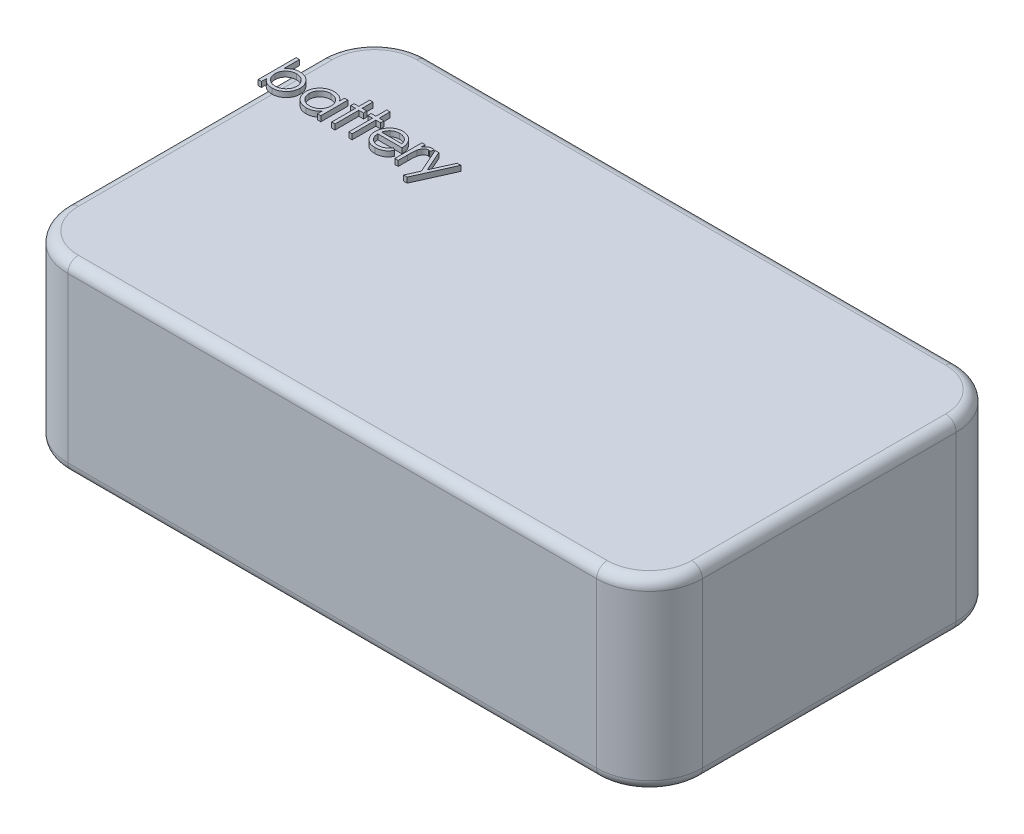
from build123d import *

# Parameters (mm, degrees)
SKETCH1_W           = 60
SKETCH1_H           = 34
BOSS_EXTRUDE1_DEPTH = 17.5
FILLET1_R           = 5
FILLET2_R           = 1
BOSS_EXTRUDE2_DEPTH = 0.5


with BuildPart() as part:
    # Sketch1 → Boss-Extrude1 (new body)
    with BuildSketch(Plane(origin=(0, 0, 0), x_dir=(1, 0, 0), z_dir=(0, 1, 0))):
        Rectangle(SKETCH1_W, SKETCH1_H)
    extrude(amount=BOSS_EXTRUDE1_DEPTH)

    # Fillet1
    fillet1_edges = [part.edges().sort_by_distance(p)[0] for p in [
        (30, 8.75, 17),
        (-30, 8.75, 17),
        (-30, 8.75, -17),
        (30, 8.75, -17),
    ]]
    fillet(fillet1_edges, radius=FILLET1_R)

    # Fillet2
    fillet2_edges = [part.edges().sort_by_distance(p)[0] for p in [
        (-30, 0, 0),
        (-30, 17.5, 0),
        (30, 0, 0),
        (0, 0, 17),
        (0, 0, -17),
        (-28.535533906, 0, 15.535533906),
        (28.535533906, 0, 15.535533906),
        (28.535533906, 0, -15.535533906),
        (-28.535533906, 0, -15.535533906),
        (0, 17.5, -17),
        (30, 17.5, 0),
        (0, 17.5, 17),
        (-28.535533906, 17.5, 15.535533906),
        (28.535533906, 17.5, 15.535533906),
        (28.535533906, 17.5, -15.535533906),
        (-28.535533906, 17.5, -15.535533906),
    ]]
    fillet(fillet2_edges, radius=FILLET2_R)

    # Sketch2 → Boss-Extrude2 (add)
    with BuildSketch(Plane(origin=(0, 17.5, 0), x_dir=(1, 0, 0), z_dir=(0, 1, 0))):
        with BuildLine():
            Line((-30.381480596, 6.382580887), (-30.381480596, 9.972324477))
            Line((-30.381480596, 9.972324477), (-30.067378032, 9.972324477))
            Line((-30.067378032, 9.972324477), (-30.067378032, 8.476130567))
            add(Edge.make_bspline(
                [(-30.067378032, 8.476130567), (-30.031984613, 8.516888499), (-29.962930593, 8.596408904), (-29.847154142, 8.700256554), (-29.725748572, 8.788309031), (-29.597790316, 8.86089515), (-29.463097383, 8.916168757), (-29.322365275, 8.956591147), (-29.175234234, 8.98097805), (-29.07491506, 8.983744123), (-29.024108801, 8.98514499)],
                knots=[0, 0, 0, 0, 0.000161815, 0.000315708, 0.000465351, 0.000611017, 0.000755934, 0.000901068, 0.001049529, 0.001201867, 0.001201867, 0.001201867, 0.001201867], degree=3))
            add(Edge.make_bspline(
                [(-29.024108801, 8.98514499), (-28.978942663, 8.983904762), (-28.889641511, 8.981452619), (-28.758359364, 8.962818124), (-28.632046089, 8.932600322), (-28.510770441, 8.890708143), (-28.395098308, 8.835125165), (-28.284039251, 8.768583858), (-28.178162267, 8.689345528), (-28.079107381, 8.598747218), (-27.987813495, 8.500390595), (-27.907900985, 8.39521028), (-27.840401289, 8.284735189), (-27.784569996, 8.169335127), (-27.741398943, 8.048538776), (-27.711656676, 7.922464577), (-27.692763212, 7.791236559), (-27.690382966, 7.701923755), (-27.689172903, 7.656519189)],
                knots=[0, 0, 0, 0, 0.000135464, 0.000267835, 0.000396906, 0.000524625, 0.000651952, 0.000781211, 0.000912462, 0.00104796, 0.001183414, 0.001314526, 0.001443549, 0.001571179, 0.00169847, 0.001827542, 0.001959218, 0.002095382, 0.002095382, 0.002095382, 0.002095382], degree=3))
            add(Edge.make_bspline(
                [(-27.689172903, 7.656519189), (-27.690409344, 7.611819171), (-27.69284741, 7.523677776), (-27.711468718, 7.393971219), (-27.742214983, 7.26913252), (-27.786176166, 7.149484263), (-27.841441105, 7.03446435), (-27.91055238, 6.925383946), (-27.99036338, 6.82034497), (-28.082694528, 6.722721338), (-28.182608081, 6.632487938), (-28.289522324, 6.554082073), (-28.400744246, 6.486364953), (-28.518007358, 6.432709506), (-28.639575399, 6.389308584), (-28.766750786, 6.359190893), (-28.898814014, 6.341617838), (-28.988532903, 6.339022271), (-29.033924506, 6.337709093)],
                knots=[0, 0, 0, 0, 0.000134063, 0.000264351, 0.000392226, 0.000519096, 0.000646094, 0.000774294, 0.000905831, 0.001041249, 0.001176798, 0.001309174, 0.001438434, 0.001566731, 0.001695345, 0.001825098, 0.001958069, 0.002094233, 0.002094233, 0.002094233, 0.002094233], degree=3))
            add(Edge.make_bspline(
                [(-29.033924506, 6.337709093), (-29.085889618, 6.339149701), (-29.187784143, 6.341974482), (-29.336836808, 6.365393462), (-29.477918357, 6.405255072), (-29.612635906, 6.458816828), (-29.739063629, 6.531345482), (-29.858004211, 6.621302232), (-29.968707584, 6.730169368), (-30.033924399, 6.813230858), (-30.067378032, 6.855838099)],
                knots=[0, 0, 0, 0, 0.00015584, 0.000305575, 0.000451192, 0.000594929, 0.000739376, 0.000887033, 0.001041224, 0.001203621, 0.001203621, 0.001203621, 0.001203621], degree=3))
            Line((-30.067378032, 6.855838099), (-30.067378032, 6.382580887))
            Line((-30.067378032, 6.382580887), (-30.381480596, 6.382580887))
        make_face()
        with BuildLine():
            add(Edge.make_bspline(
                [(-29.036728993, 6.651811657), (-28.990814641, 6.653445286), (-28.900187012, 6.656669809), (-28.767143221, 6.681843432), (-28.639829012, 6.723727546), (-28.51888593, 6.781011255), (-28.406206618, 6.853033289), (-28.305553984, 6.94017946), (-28.216074274, 7.039680974), (-28.141422498, 7.151914668), (-28.079096254, 7.271365637), (-28.036282977, 7.397019938), (-28.007563256, 7.525514727), (-28.004710958, 7.612660772), (-28.003275467, 7.656519189)],
                knots=[0, 0, 0, 0, 0.000137677, 0.000271753, 0.000404561, 0.000538791, 0.000672205, 0.000804452, 0.00093703, 0.001072374, 0.001207834, 0.001339988, 0.001469657, 0.001601037, 0.001601037, 0.001601037, 0.001601037], degree=3))
            add(Edge.make_bspline(
                [(-28.003275467, 7.656519189), (-28.005163211, 7.700334731), (-28.008931163, 7.787790891), (-28.035305945, 7.917440559), (-28.081363735, 8.043028183), (-28.142481759, 8.164206172), (-28.218349744, 8.277213972), (-28.307355707, 8.378704099), (-28.409237513, 8.466264084), (-28.522060933, 8.539254155), (-28.642241124, 8.598813708), (-28.768731757, 8.639658733), (-28.89888988, 8.666396921), (-28.987285373, 8.669486049), (-29.031821141, 8.671042426)],
                knots=[0, 0, 0, 0, 0.000131426, 0.000262328, 0.000394949, 0.000531659, 0.000668557, 0.000802185, 0.00093542, 0.001070185, 0.001204391, 0.001336533, 0.001467986, 0.001601464, 0.001601464, 0.001601464, 0.001601464], degree=3))
            add(Edge.make_bspline(
                [(-29.031821141, 8.671042426), (-29.077288648, 8.669486928), (-29.167532424, 8.666399582), (-29.300700647, 8.639611758), (-29.430763931, 8.598564146), (-29.555051462, 8.539632797), (-29.670905518, 8.467521336), (-29.77451813, 8.382781137), (-29.863849688, 8.286001229), (-29.937393458, 8.177495427), (-29.995798257, 8.060310391), (-30.037582005, 7.935298188), (-30.062581652, 7.803116876), (-30.065759784, 7.71248367), (-30.067378032, 7.666334894)],
                knots=[0, 0, 0, 0, 0.000136278, 0.000270483, 0.00040596, 0.000544592, 0.000681933, 0.000814436, 0.000944937, 0.001075619, 0.00120637, 0.001336516, 0.001469903, 0.00160828, 0.00160828, 0.00160828, 0.00160828], degree=3))
            add(Edge.make_bspline(
                [(-30.067378032, 7.666334894), (-30.066418361, 7.630997075), (-30.064529426, 7.561441066), (-30.050099057, 7.459313375), (-30.027143396, 7.361580283), (-29.994799902, 7.268135288), (-29.952298667, 7.179508848), (-29.901088401, 7.095012768), (-29.840136755, 7.015409489), (-29.771230165, 6.940894169), (-29.695267785, 6.873084755), (-29.613744666, 6.81430653), (-29.528326735, 6.76369234), (-29.438036764, 6.723347497), (-29.343925474, 6.690420976), (-29.245027133, 6.668687231), (-29.142355708, 6.653712192), (-29.072308611, 6.652451839), (-29.036728993, 6.651811657)],
                knots=[0, 0, 0, 0, 0.000105983, 0.000208608, 0.000308773, 0.00040678, 0.000504626, 0.000603105, 0.000702667, 0.000804872, 0.000907174, 0.001007588, 0.001105951, 0.001204477, 0.001303809, 0.001404498, 0.001507818, 0.001614471, 0.001614471, 0.001614471, 0.001614471], degree=3))
        make_face(mode=Mode.SUBTRACT)
        with BuildLine():
            Line((-24.458403673, 8.940273195), (-24.458403673, 6.382580887))
            Line((-24.458403673, 6.382580887), (-24.772506237, 6.382580887))
            Line((-24.772506237, 6.382580887), (-24.772506237, 6.82498874))
            add(Edge.make_bspline(
                [(-24.772506237, 6.82498874), (-24.807925027, 6.784949146), (-24.877045243, 6.706811375), (-24.992486361, 6.604729202), (-25.114854539, 6.520350881), (-25.24355586, 6.452200965), (-25.378474103, 6.401008909), (-25.51931019, 6.36462275), (-25.666121571, 6.341228915), (-25.766373926, 6.338892893), (-25.817177711, 6.337709093)],
                knots=[0, 0, 0, 0, 0.000160263, 0.000312755, 0.000460949, 0.000605216, 0.000748578, 0.000892786, 0.001041028, 0.001193333, 0.001193333, 0.001193333, 0.001193333], degree=3))
            add(Edge.make_bspline(
                [(-25.817177711, 6.337709093), (-25.862345665, 6.338935465), (-25.95141887, 6.341353925), (-26.082447947, 6.360116229), (-26.208540196, 6.390246851), (-26.329814769, 6.43214774), (-26.445486914, 6.487728562), (-26.556547011, 6.55426981), (-26.662419703, 6.63351064), (-26.761491242, 6.724098668), (-26.852723243, 6.822493655), (-26.932784515, 6.927439202), (-26.999537595, 7.038481506), (-27.055357676, 7.15421466), (-27.09835402, 7.27552958), (-27.128327654, 7.402006747), (-27.147068101, 7.533496621), (-27.149485562, 7.623036144), (-27.150711365, 7.668438259)],
                knots=[0, 0, 0, 0, 0.000135464, 0.00026714, 0.000396211, 0.000523931, 0.000651257, 0.000780517, 0.000911767, 0.001047265, 0.00118272, 0.001313831, 0.001442491, 0.001570752, 0.001698704, 0.001827775, 0.001960146, 0.00209631, 0.00209631, 0.00209631, 0.00209631], degree=3))
            add(Edge.make_bspline(
                [(-27.150711365, 7.668438259), (-27.149458394, 7.712901963), (-27.146981337, 7.800804306), (-27.128528117, 7.930083004), (-27.097497108, 8.054601265), (-27.053949261, 8.173958208), (-26.998107306, 8.288298258), (-26.930179219, 8.397702283), (-26.850160094, 8.502471681), (-26.757907687, 8.600142908), (-26.657972917, 8.690363522), (-26.551064186, 8.768772567), (-26.439840904, 8.836489416), (-26.322577894, 8.890142892), (-26.201010789, 8.933551997), (-26.074057343, 8.963584965), (-25.942245765, 8.981282286), (-25.852755273, 8.98384505), (-25.807362006, 8.98514499)],
                knots=[0, 0, 0, 0, 0.000133363, 0.00026365, 0.000390846, 0.000517716, 0.000644083, 0.000771912, 0.000903449, 0.001038867, 0.001174416, 0.001306792, 0.001436052, 0.00156435, 0.001692963, 0.001822716, 0.001954992, 0.002091156, 0.002091156, 0.002091156, 0.002091156], degree=3))
            add(Edge.make_bspline(
                [(-25.807362006, 8.98514499), (-25.755162147, 8.983707238), (-25.652800687, 8.980887876), (-25.503072678, 8.957425148), (-25.3614282, 8.917786681), (-25.226773848, 8.863869183), (-25.099593162, 8.792220454), (-24.981090177, 8.701840493), (-24.870024694, 8.593299306), (-24.805644402, 8.509928862), (-24.772506237, 8.467015984)],
                knots=[0, 0, 0, 0, 0.00015654, 0.000306968, 0.000453261, 0.000596998, 0.000741098, 0.000889738, 0.001042937, 0.001205434, 0.001205434, 0.001205434, 0.001205434], degree=3))
            Line((-24.772506237, 8.467015984), (-24.772506237, 8.940273195))
            Line((-24.772506237, 8.940273195), (-24.458403673, 8.940273195))
        make_face()
        with BuildLine():
            add(Edge.make_bspline(
                [(-25.803155275, 8.671042426), (-25.849069613, 8.669408788), (-25.939697213, 8.666184247), (-26.072741215, 8.641010752), (-26.200054629, 8.599126158), (-26.321000703, 8.541844256), (-26.43366892, 8.46981552), (-26.534362591, 8.382694137), (-26.623905292, 8.282857122), (-26.699213556, 8.170755012), (-26.760604053, 8.050576921), (-26.803771085, 7.924952483), (-26.832240333, 7.796147505), (-26.835148853, 7.708784819), (-26.836608801, 7.66493265)],
                knots=[0, 0, 0, 0, 0.000137677, 0.000271753, 0.000404561, 0.000538791, 0.000672205, 0.000804452, 0.00093703, 0.001073348, 0.00120849, 0.001340643, 0.001470999, 0.001602378, 0.001602378, 0.001602378, 0.001602378], degree=3))
            add(Edge.make_bspline(
                [(-26.836608801, 7.66493265), (-26.834743908, 7.621342543), (-26.831021431, 7.534333187), (-26.804270736, 7.40535261), (-26.759390863, 7.279698568), (-26.6981488, 7.158437575), (-26.621462175, 7.045853475), (-26.532573523, 6.944113352), (-26.430623241, 6.856623764), (-26.317695734, 6.78338619), (-26.197087764, 6.724223669), (-26.070253833, 6.68305803), (-25.939578194, 6.656480249), (-25.850725861, 6.653375772), (-25.805959762, 6.651811657)],
                knots=[0, 0, 0, 0, 0.000130727, 0.000260941, 0.000393327, 0.000530037, 0.000667328, 0.000800955, 0.000934191, 0.001068956, 0.001203792, 0.001335934, 0.001468075, 0.001602253, 0.001602253, 0.001602253, 0.001602253], degree=3))
            add(Edge.make_bspline(
                [(-25.805959762, 6.651811657), (-25.76051326, 6.653471621), (-25.670124673, 6.656773124), (-25.536685965, 6.68205439), (-25.407191002, 6.723823188), (-25.283403774, 6.781722315), (-25.168087643, 6.85347967), (-25.064589765, 6.937486762), (-24.977073797, 7.035189946), (-24.902881187, 7.142566399), (-24.844705771, 7.260278395), (-24.802329711, 7.385612586), (-24.777275806, 7.518573334), (-24.774118076, 7.609437261), (-24.772506237, 7.655818067)],
                knots=[0, 0, 0, 0, 0.000136278, 0.000271043, 0.000405851, 0.000543552, 0.000679927, 0.000812429, 0.000941985, 0.001072088, 0.00120284, 0.001334538, 0.001467925, 0.001607002, 0.001607002, 0.001607002, 0.001607002], degree=3))
            add(Edge.make_bspline(
                [(-24.772506237, 7.655818067), (-24.773465893, 7.691155897), (-24.775354801, 7.760711931), (-24.78978537, 7.862839448), (-24.812740296, 7.960573174), (-24.845086466, 8.054015863), (-24.887577751, 8.142650879), (-24.938825517, 8.227114639), (-24.999730967, 8.30696785), (-25.069313663, 8.381110921), (-25.145478865, 8.448737384), (-25.226073406, 8.509101624), (-25.312052153, 8.558690397), (-25.40196919, 8.599731669), (-25.495980524, 8.632390819), (-25.594851144, 8.654178512), (-25.697530131, 8.669138833), (-25.767576186, 8.670401214), (-25.803155275, 8.671042426)],
                knots=[0, 0, 0, 0, 0.000105983, 0.000208608, 0.000308773, 0.00040678, 0.000504626, 0.000603105, 0.000702667, 0.00080535, 0.000907651, 0.001007914, 0.001106881, 0.00120477, 0.001304102, 0.001404791, 0.00150811, 0.001614764, 0.001614764, 0.001614764, 0.001614764], degree=3))
        make_face(mode=Mode.SUBTRACT)
        Polygon((-23.426352391, 9.972324477), (-23.112249826, 9.972324477), (-23.112249826, 8.940273195), (-22.663531878, 8.940273195), (-22.663531878, 8.626170631), (-23.112249826, 8.626170631), (-23.112249826, 6.382580887), (-23.426352391, 6.382580887), (-23.426352391, 8.626170631), (-23.875070339, 8.626170631), (-23.875070339, 8.940273195), (-23.426352391, 8.940273195), align=None)
        Polygon((-21.810967775, 9.972324477), (-21.496865211, 9.972324477), (-21.496865211, 8.940273195), (-21.048147262, 8.940273195), (-21.048147262, 8.626170631), (-21.496865211, 8.626170631), (-21.496865211, 6.382580887), (-21.810967775, 6.382580887), (-21.810967775, 8.626170631), (-22.259685724, 8.626170631), (-22.259685724, 8.940273195), (-21.810967775, 8.940273195), align=None)
        with BuildLine():
            Line((-18.41052707, 7.190273195), (-18.131480596, 7.04373874))
            add(Edge.make_bspline(
                [(-18.131480596, 7.04373874), (-18.153717191, 7.004295409), (-18.196980799, 6.927554306), (-18.271381547, 6.822122445), (-18.34937362, 6.72727473), (-18.434477588, 6.645545075), (-18.524147267, 6.57429369), (-18.618879922, 6.511955866), (-18.719168739, 6.458837345), (-18.825018464, 6.414084817), (-18.937318015, 6.379675323), (-19.056339532, 6.355371102), (-19.182311027, 6.340347834), (-19.268657207, 6.338602693), (-19.31287082, 6.337709093)],
                knots=[0, 0, 0, 0, 0.000135759, 0.000264133, 0.000386579, 0.000503597, 0.000617365, 0.000729763, 0.000843304, 0.000957371, 0.001074023, 0.001195027, 0.001321389, 0.001453992, 0.001453992, 0.001453992, 0.001453992], degree=3))
            add(Edge.make_bspline(
                [(-19.31287082, 6.337709093), (-19.362012798, 6.338856268), (-19.457874559, 6.341094075), (-19.597414306, 6.360386539), (-19.728793725, 6.391858898), (-19.852005428, 6.435824439), (-19.966747681, 6.493251763), (-20.073248535, 6.563211245), (-20.172068061, 6.6453435), (-20.260092271, 6.740359943), (-20.339336153, 6.842041901), (-20.409261973, 6.947997785), (-20.467719404, 7.05796101), (-20.515272014, 7.171231534), (-20.553676879, 7.287095427), (-20.580443583, 7.406606895), (-20.595873331, 7.529442479), (-20.598237777, 7.612539815), (-20.599429314, 7.654415823)],
                knots=[0, 0, 0, 0, 0.000147371, 0.000287478, 0.000421649, 0.000552053, 0.000679042, 0.000805636, 0.000933558, 0.00106351, 0.001193382, 0.001319977, 0.001443869, 0.001566405, 0.001688128, 0.001809576, 0.001933238, 0.002058864, 0.002058864, 0.002058864, 0.002058864], degree=3))
            add(Edge.make_bspline(
                [(-20.599429314, 7.654415823), (-20.598370172, 7.693710654), (-20.596271094, 7.771587818), (-20.583040307, 7.886853363), (-20.559592014, 7.998881816), (-20.52741569, 8.107766263), (-20.485864443, 8.213324397), (-20.435032224, 8.315620461), (-20.374839846, 8.414545601), (-20.328367173, 8.476948735), (-20.30495816, 8.50838217)],
                knots=[0, 0, 0, 0, 0.000117891, 0.000233644, 0.000347498, 0.000460856, 0.000573868, 0.000687374, 0.000803169, 0.000920699, 0.000920699, 0.000920699, 0.000920699], degree=3))
            add(Edge.make_bspline(
                [(-20.30495816, 8.50838217), (-20.273250477, 8.54625104), (-20.21083953, 8.62078919), (-20.105283175, 8.718727516), (-19.990982979, 8.800771291), (-19.869371353, 8.868778427), (-19.739034879, 8.920452074), (-19.601725588, 8.958959656), (-19.455880001, 8.980537667), (-19.35617478, 8.983585501), (-19.30515848, 8.98514499)],
                knots=[0, 0, 0, 0, 0.000148071, 0.000291452, 0.00043058, 0.000569298, 0.000708346, 0.00085021, 0.000996268, 0.001149307, 0.001149307, 0.001149307, 0.001149307], degree=3))
            add(Edge.make_bspline(
                [(-19.30515848, 8.98514499), (-19.252710875, 8.983790941), (-19.149820629, 8.981134606), (-18.999788508, 8.956508272), (-18.857827791, 8.917455718), (-18.723995287, 8.862301927), (-18.598277426, 8.791142376), (-18.481491377, 8.703000534), (-18.371639864, 8.600582447), (-18.307731285, 8.521819237), (-18.275210564, 8.481739541)],
                knots=[0, 0, 0, 0, 0.000157241, 0.00030847, 0.000454763, 0.000598116, 0.000741606, 0.000886879, 0.001036172, 0.001190853, 0.001190853, 0.001190853, 0.001190853], degree=3))
            add(Edge.make_bspline(
                [(-18.275210564, 8.481739541), (-18.253083625, 8.45153596), (-18.208977032, 8.391329841), (-18.153729932, 8.293158684), (-18.105772537, 8.19044809), (-18.067439576, 8.081537793), (-18.036400075, 7.967718213), (-18.013943256, 7.848175668), (-18.000773638, 7.722945756), (-17.99818494, 7.637619201), (-17.996865211, 7.594119349)],
                knots=[0, 0, 0, 0, 0.000112234, 0.000223721, 0.000337279, 0.000451932, 0.000569628, 0.000690912, 0.000816421, 0.00094695, 0.00094695, 0.00094695, 0.00094695], degree=3))
            Line((-17.996865211, 7.594119349), (-20.28532675, 7.594119349))
            add(Edge.make_bspline(
                [(-20.28532675, 7.594119349), (-20.283787143, 7.560418885), (-20.280759569, 7.494148281), (-20.266644426, 7.397177498), (-20.244395652, 7.304804156), (-20.21312659, 7.217721114), (-20.175259744, 7.134790986), (-20.128874028, 7.056628949), (-20.073534474, 6.983591019), (-20.011808774, 6.915023882), (-19.943101679, 6.85396312), (-19.870818932, 6.799311344), (-19.793925367, 6.753505748), (-19.713027283, 6.716325858), (-19.628255498, 6.687219542), (-19.539583303, 6.667351721), (-19.447185187, 6.654044614), (-19.384199453, 6.652564949), (-19.352133641, 6.651811657)],
                knots=[0, 0, 0, 0, 0.000101159, 0.000198924, 0.000293472, 0.000385722, 0.000476069, 0.000566611, 0.000657757, 0.000750573, 0.000842919, 0.000933083, 0.001022062, 0.001110842, 0.001199752, 0.001290403, 0.001383113, 0.001479259, 0.001479259, 0.001479259, 0.001479259], degree=3))
            add(Edge.make_bspline(
                [(-19.352133641, 6.651811657), (-19.320782493, 6.652419713), (-19.258575802, 6.653626214), (-19.165934945, 6.665358125), (-19.074795417, 6.684328401), (-18.985534434, 6.710218391), (-18.899963588, 6.741795243), (-18.820718038, 6.779898101), (-18.747837822, 6.822047848), (-18.679720856, 6.870257523), (-18.613649862, 6.92926571), (-18.548107376, 7.002901431), (-18.477830723, 7.089988958), (-18.43384113, 7.155534624), (-18.41052707, 7.190273195)],
                knots=[0, 0, 0, 0, 9.4016e-05, 0.000186545, 0.000279636, 0.000373054, 0.000465125, 0.000552934, 0.000636508, 0.000717442, 0.000802858, 0.000901616, 0.001012865, 0.001138311, 0.001138311, 0.001138311, 0.001138311], degree=3))
        make_face()
        with BuildLine():
            add(Edge.make_bspline(
                [(-18.310967775, 7.908221913), (-18.3224644, 7.949884787), (-18.344591701, 8.030072407), (-18.390828066, 8.141113298), (-18.442899606, 8.239801199), (-18.504521338, 8.325380832), (-18.574340063, 8.401384345), (-18.654985246, 8.46780293), (-18.74542114, 8.527220381), (-18.84518028, 8.577372881), (-18.950822065, 8.620062739), (-19.061428257, 8.648687855), (-19.174286045, 8.668297397), (-19.250620331, 8.670123506), (-19.289032679, 8.671042426)],
                knots=[0, 0, 0, 0, 0.000129543, 0.000249328, 0.000360065, 0.000463575, 0.000564789, 0.000668832, 0.000776175, 0.000888744, 0.001003316, 0.001117263, 0.001230914, 0.001346035, 0.001346035, 0.001346035, 0.001346035], degree=3))
            add(Edge.make_bspline(
                [(-19.289032679, 8.671042426), (-19.320382118, 8.670430754), (-19.382353367, 8.669221608), (-19.473654435, 8.657751479), (-19.561334134, 8.638791634), (-19.646039421, 8.612826678), (-19.72666029, 8.578218075), (-19.804855058, 8.537634848), (-19.878635454, 8.488093265), (-19.92477675, 8.45033441), (-19.948087166, 8.431258772)],
                knots=[0, 0, 0, 0, 9.4016e-05, 0.000185849, 0.000275511, 0.000362884, 0.000451173, 0.00053836, 0.000626838, 0.000717174, 0.000717174, 0.000717174, 0.000717174], degree=3))
            add(Edge.make_bspline(
                [(-19.948087166, 8.431258772), (-19.964780448, 8.416164456), (-19.998563582, 8.38561724), (-20.043704104, 8.332988034), (-20.086924577, 8.276236472), (-20.126258229, 8.213191347), (-20.162335816, 8.144570568), (-20.196095793, 8.070952933), (-20.226482205, 7.991779803), (-20.243578315, 7.936607363), (-20.252374025, 7.908221913)],
                knots=[0, 0, 0, 0, 6.7454e-05, 0.00013651, 0.000207604, 0.000281328, 0.000359112, 0.000440057, 0.000524171, 0.000613305, 0.000613305, 0.000613305, 0.000613305], degree=3))
            Line((-20.252374025, 7.908221913), (-18.310967775, 7.908221913))
        make_face(mode=Mode.SUBTRACT)
        with BuildLine():
            Line((-17.458403673, 8.940273195), (-17.144301109, 8.940273195))
            Line((-17.144301109, 8.940273195), (-17.144301109, 8.563770791))
            add(Edge.make_bspline(
                [(-17.144301109, 8.563770791), (-17.12111235, 8.59882662), (-17.076764029, 8.665870619), (-17.003051099, 8.75453992), (-16.927547768, 8.827954967), (-16.849892581, 8.886458485), (-16.769514481, 8.930271604), (-16.688177529, 8.962364639), (-16.604602059, 8.981341954), (-16.548440135, 8.983875613), (-16.520302711, 8.98514499)],
                knots=[0, 0, 0, 0, 0.000126023, 0.000241017, 0.000345147, 0.000441342, 0.00053171, 0.000618946, 0.000702978, 0.000787349, 0.000787349, 0.000787349, 0.000787349], degree=3))
            add(Edge.make_bspline(
                [(-16.520302711, 8.98514499), (-16.498476385, 8.983954463), (-16.453567299, 8.981504878), (-16.38558471, 8.964294053), (-16.315541258, 8.93681603), (-16.27039887, 8.910975808), (-16.246865211, 8.897504766)],
                knots=[0, 0, 0, 0, 6.5445e-05, 0.000134658, 0.00020926, 0.000290509, 0.000290509, 0.000290509, 0.000290509], degree=3))
            Line((-16.246865211, 8.897504766), (-16.419341173, 8.625469509))
            add(Edge.make_bspline(
                [(-16.419341173, 8.625469509), (-16.434450194, 8.632209775), (-16.463130008, 8.645004091), (-16.505084575, 8.660146101), (-16.543765911, 8.669062017), (-16.56840947, 8.670412734), (-16.579898064, 8.671042426)],
                knots=[0, 0, 0, 0, 4.9621e-05, 9.4191e-05, 0.00013366, 0.000168129, 0.000168129, 0.000168129, 0.000168129], degree=3))
            add(Edge.make_bspline(
                [(-16.579898064, 8.671042426), (-16.605103797, 8.669362389), (-16.656516187, 8.665935599), (-16.732000687, 8.638996792), (-16.805247892, 8.595471551), (-16.863419554, 8.54720044), (-16.908461807, 8.500652642), (-16.940602033, 8.46000424), (-16.97008478, 8.414425608), (-16.998255, 8.364695924), (-17.023921294, 8.309966078), (-17.047875964, 8.250782865), (-17.069534826, 8.187077736), (-17.081885071, 8.142695216), (-17.088211365, 8.119960695)],
                knots=[0, 0, 0, 0, 7.549e-05, 0.000153978, 0.000237553, 0.000330197, 0.000379784, 0.000431685, 0.000485357, 0.000542493, 0.000603021, 0.000666557, 0.00073396, 0.000804745, 0.000804745, 0.000804745, 0.000804745], degree=3))
            add(Edge.make_bspline(
                [(-17.088211365, 8.119960695), (-17.092943758, 8.099683522), (-17.10342565, 8.054771123), (-17.113617188, 7.979422598), (-17.123686706, 7.890398939), (-17.130783324, 7.787452347), (-17.137361366, 7.670839903), (-17.141071449, 7.540383957), (-17.144174589, 7.395950606), (-17.144257656, 7.294976253), (-17.144301109, 7.242156208)],
                knots=[0, 0, 0, 0, 6.2435e-05, 0.000138289, 0.000227871, 0.000331224, 0.000447781, 0.000578258, 0.000722716, 0.000881171, 0.000881171, 0.000881171, 0.000881171], degree=3))
            Line((-17.144301109, 7.242156208), (-17.144301109, 6.382580887))
            Line((-17.144301109, 6.382580887), (-17.458403673, 6.382580887))
            Line((-17.458403673, 6.382580887), (-17.458403673, 8.940273195))
        make_face()
        Polygon((-16.201993416, 8.940273195), (-15.863351589, 8.940273195), (-14.997466173, 6.9813389), (-14.118259442, 8.940273195), (-13.778916493, 8.940273195), (-15.349429314, 5.440273195), (-15.688772262, 5.440273195), (-15.167838769, 6.600629766), align=None)
    extrude(amount=BOSS_EXTRUDE2_DEPTH)


solid = part.part
